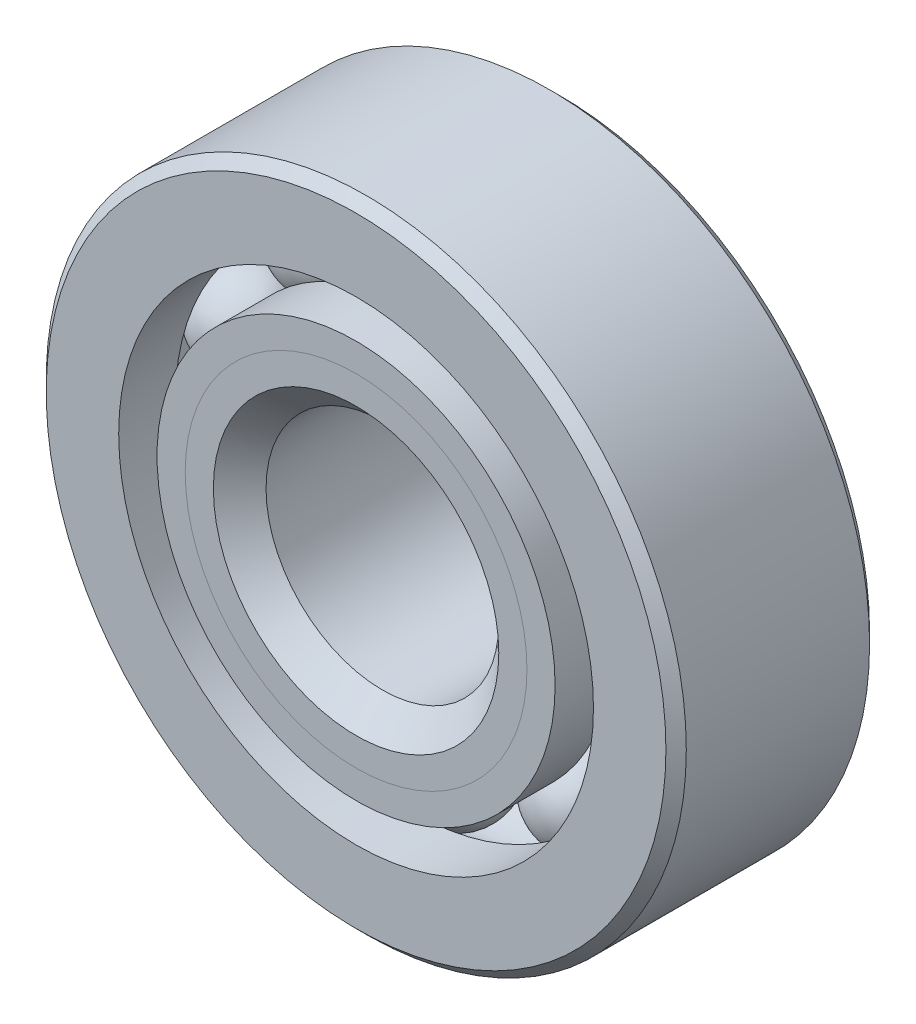
from build123d import *

# Parameters (mm, degrees)
CIRPATTERN1_COUNT = 10


with BuildPart() as part:
    # Sketch1 → Revolve1 (revolve)
    with BuildSketch(Plane(origin=(0, 0, 0), x_dir=(0, 0, -1), z_dir=(1, 0, 0))):
        with BuildLine():
            Line((3.15, 11), (-3.15, 11))
            Line((-3.15, 11), (-3.5, 10.65))
            Line((-3.5, 10.65), (-3.5, 8.159340659))
            Line((-3.5, 8.159340659), (-1.555555556, 8.159340659))
            ThreePointArc((-1.555555556, 8.159340659), (0, 9.189521587), (1.555555556, 8.159340659))
            Line((1.555555556, 8.159340659), (3.5, 8.159340659))
            Line((3.5, 8.159340659), (3.5, 10.65))
            Line((3.5, 10.65), (3.15, 11))
        make_face()
    revolve(axis=Axis((0, 0, 3.5), (0, 0, -1)))


with BuildPart() as body_2:
    # Sketch2 → Revolve2 (revolve)
    with BuildSketch(Plane(origin=(0, 0, 0), x_dir=(0, 0, -1), z_dir=(1, 0, 0))):
        with BuildLine():
            Line((-3.5, 6.840659341), (-1.555555556, 6.840659341))
            ThreePointArc((-1.555555556, 6.840659341), (-0.932875371, 6.091374168), (0, 5.810478413))
            Line((0, 5.810478413), (0, 4.905239207))
            Line((0, 4.905239207), (-2.532289933, 4.905239207))
            Line((-2.532289933, 4.905239207), (-3.5, 5.872949274))
            Line((-3.5, 5.872949274), (-3.5, 6.840659341))
        make_face()
    revolve(axis=Axis((0, 0, 3.5), (0, 0, -1)))


with BuildPart() as body_3:
    # Sketch3 → Revolve3 (revolve)
    with BuildSketch(Plane(origin=(0, 0, 0), x_dir=(0, 0, -1), z_dir=(1, 0, 0))):
        with BuildLine():
            Line((-3.5, 5.872949274), (-2.532289933, 4.905239207))
            Line((-2.532289933, 4.905239207), (0, 4.905239207))
            Line((0, 4.905239207), (0, 5.810478413))
            ThreePointArc((0, 5.810478413), (0.932875371, 6.091374168), (1.555555556, 6.840659341))
            Line((1.555555556, 6.840659341), (3.5, 6.840659341))
            Line((3.5, 6.840659341), (3.5, 4.35))
            Line((3.5, 4.35), (3.15, 4))
            Line((3.15, 4), (-2.594760793, 4))
            Line((-2.594760793, 4), (-3.5, 4.905239207))
            Line((-3.5, 4.905239207), (-3.5, 5.872949274))
        make_face()
    revolve(axis=Axis((0, 0, 3.5), (0, 0, -1)))


with BuildPart() as body_4:
    # Sketch4 → Revolve4 (revolve)
    with BuildSketch(Plane(origin=(0, 0, 0), x_dir=(0, 0, -1), z_dir=(1, 0, 0))):
        with BuildLine():
            Line((-1.689521587, 7.5), (1.689521587, 7.5))
            ThreePointArc((1.689521587, 7.5), (0, 9.189521587), (-1.689521587, 7.5))
        make_face()
    revolve(axis=Axis((0, 7.5, 1.689521587), (0, 0, -1)))


with BuildPart() as cirpattern1_1:
    # CirPattern1: pattern copy
    add(body_4.part.rotate(Axis((0, 0, -3.5), (0, 0, 1)), 1 * 360 / CIRPATTERN1_COUNT))


with BuildPart() as cirpattern1_2:
    # CirPattern1: pattern copy
    add(body_4.part.rotate(Axis((0, 0, -3.5), (0, 0, 1)), 2 * 360 / CIRPATTERN1_COUNT))


with BuildPart() as cirpattern1_3:
    # CirPattern1: pattern copy
    add(body_4.part.rotate(Axis((0, 0, -3.5), (0, 0, 1)), 3 * 360 / CIRPATTERN1_COUNT))


with BuildPart() as cirpattern1_4:
    # CirPattern1: pattern copy
    add(body_4.part.rotate(Axis((0, 0, -3.5), (0, 0, 1)), 4 * 360 / CIRPATTERN1_COUNT))


with BuildPart() as cirpattern1_5:
    # CirPattern1: pattern copy
    add(body_4.part.rotate(Axis((0, 0, -3.5), (0, 0, 1)), 5 * 360 / CIRPATTERN1_COUNT))


with BuildPart() as cirpattern1_6:
    # CirPattern1: pattern copy
    add(body_4.part.rotate(Axis((0, 0, -3.5), (0, 0, 1)), 6 * 360 / CIRPATTERN1_COUNT))


with BuildPart() as cirpattern1_7:
    # CirPattern1: pattern copy
    add(body_4.part.rotate(Axis((0, 0, -3.5), (0, 0, 1)), 7 * 360 / CIRPATTERN1_COUNT))


with BuildPart() as cirpattern1_8:
    # CirPattern1: pattern copy
    add(body_4.part.rotate(Axis((0, 0, -3.5), (0, 0, 1)), 8 * 360 / CIRPATTERN1_COUNT))


with BuildPart() as cirpattern1_9:
    # CirPattern1: pattern copy
    add(body_4.part.rotate(Axis((0, 0, -3.5), (0, 0, 1)), 9 * 360 / CIRPATTERN1_COUNT))


solid = Compound([part.part, body_2.part, body_3.part, body_4.part, cirpattern1_1.part, cirpattern1_2.part, cirpattern1_3.part, cirpattern1_4.part, cirpattern1_5.part, cirpattern1_6.part, cirpattern1_7.part, cirpattern1_8.part, cirpattern1_9.part])
